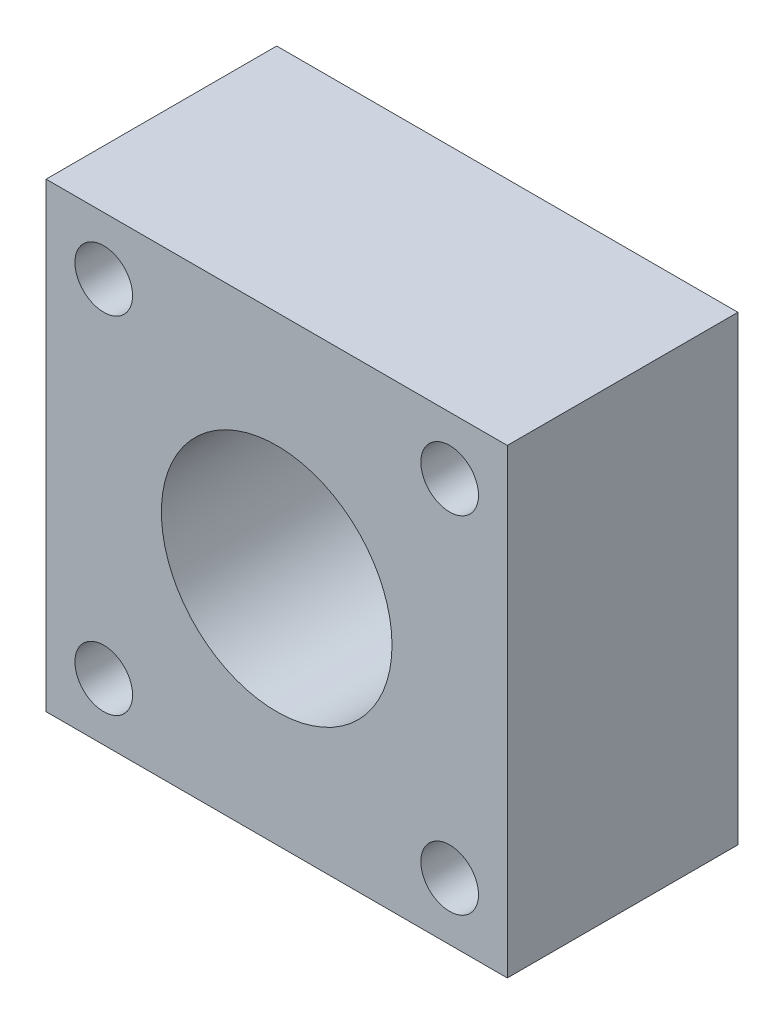
from build123d import *

# Parameters (mm, degrees)
SKETCH4_W           = 50.8
SKETCH4_H           = 50.8
BOSS_EXTRUDE2_DEPTH = 25.4
SKETCH5_R           = 3.175
SKETCH5_R_2         = 12.7
CUT_EXTRUDE5_DEPTH  = 25.4


with BuildPart() as part:
    # Sketch4 → Boss-Extrude2 (new body)
    with BuildSketch(Plane.XY):
        Rectangle(SKETCH4_W, SKETCH4_H)
    extrude(amount=BOSS_EXTRUDE2_DEPTH)

    # Sketch5 → Cut-Extrude5 (cut)
    with BuildSketch(Plane.XY.offset(25.4)):
        with Locations((19.05, 19.05)):
            Circle(SKETCH5_R)
        Circle(SKETCH5_R_2)
        with Locations((-19.05, 19.05)):
            Circle(SKETCH5_R)
        with Locations((19.05, -19.05)):
            Circle(SKETCH5_R)
        with Locations((-19.05, -19.05)):
            Circle(SKETCH5_R)
    extrude(amount=-CUT_EXTRUDE5_DEPTH, mode=Mode.SUBTRACT)


solid = part.part
